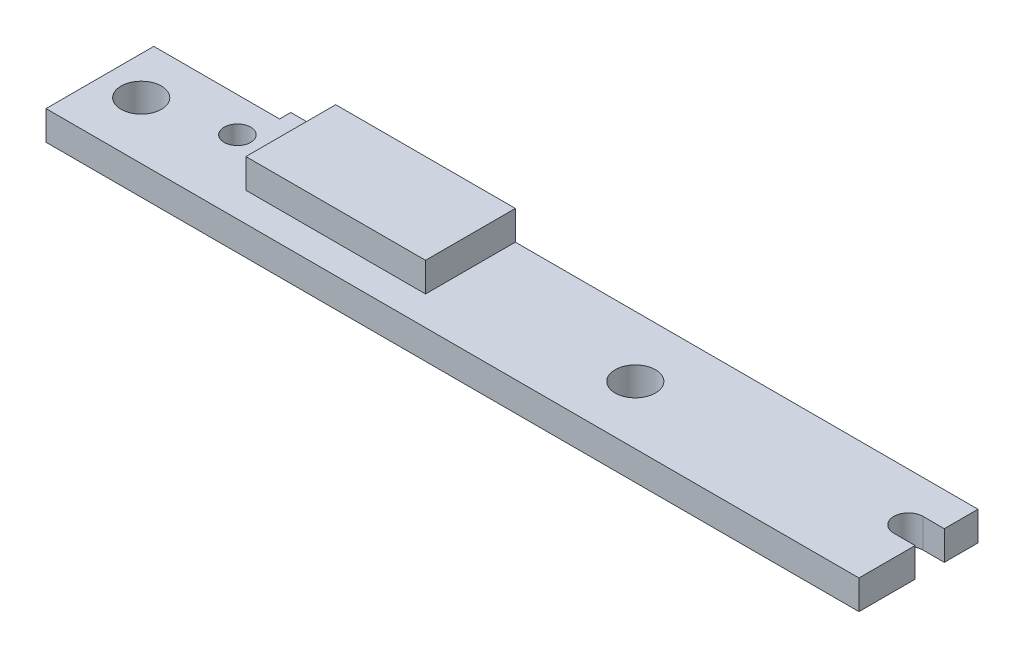
from build123d import *

# Parameters (mm, degrees)
SKETCH1_R                = 1.143
SKETCH1_R_2              = 0.75
BOSS_EXTRUDE1_DEPTH      = 1.651
SKETCH2_W                = 10.16
SKETCH2_H                = 5.08
BOSS_EXTRUDE2_DEPTH      = 1.651
BOSS_EXTRUDE2_DEPTH_BACK = 1.651


with BuildPart() as part:
    # Sketch1 → Boss-Extrude1 (new body)
    with BuildSketch(Plane(origin=(0, 0, 0), x_dir=(1, 0, 0), z_dir=(0, 1, 0))):
        with BuildLine():
            Line((0, 6.096), (0, 0))
            Line((0, 0), (45.974, 0))
            Line((45.974, 0), (45.974, 3.175))
            Line((45.974, 3.175), (44.7675, 3.175))
            ThreePointArc((44.7675, 3.175), (43.942, 4.0005), (44.7675, 4.826))
            Line((44.7675, 4.826), (45.974, 4.826))
            Line((45.974, 4.826), (45.974, 6.731))
            Line((45.974, 6.731), (19.812, 6.731))
            Line((19.812, 6.731), (19.812, 1.651))
            Line((19.812, 1.651), (9.652, 1.651))
            Line((9.652, 1.651), (9.652, 6.731))
            Line((9.652, 6.731), (7.112, 6.731))
            Line((7.112, 6.731), (7.112, 6.096))
            Line((7.112, 6.096), (0, 6.096))
        make_face()
        with Locations((2.159, 3.2258)):
            Circle(SKETCH1_R, mode=Mode.SUBTRACT)
        with Locations((30.0228, 3.302)):
            Circle(SKETCH1_R, mode=Mode.SUBTRACT)
        with Locations((6.6936, 4.1282)):
            Circle(SKETCH1_R_2, mode=Mode.SUBTRACT)
    extrude(amount=BOSS_EXTRUDE1_DEPTH)

    # Sketch2 → Boss-Extrude2 (add, two sides)
    with BuildSketch(Plane(origin=(0, 1.651, 0), x_dir=(1, 0, 0), z_dir=(0, 1, 0))) as boss_extrude2_sk:
        with Locations((14.732, 4.191)):
            Rectangle(SKETCH2_W, SKETCH2_H)
    extrude(amount=BOSS_EXTRUDE2_DEPTH)
    extrude(boss_extrude2_sk.sketch, amount=-BOSS_EXTRUDE2_DEPTH_BACK)


solid = part.part
